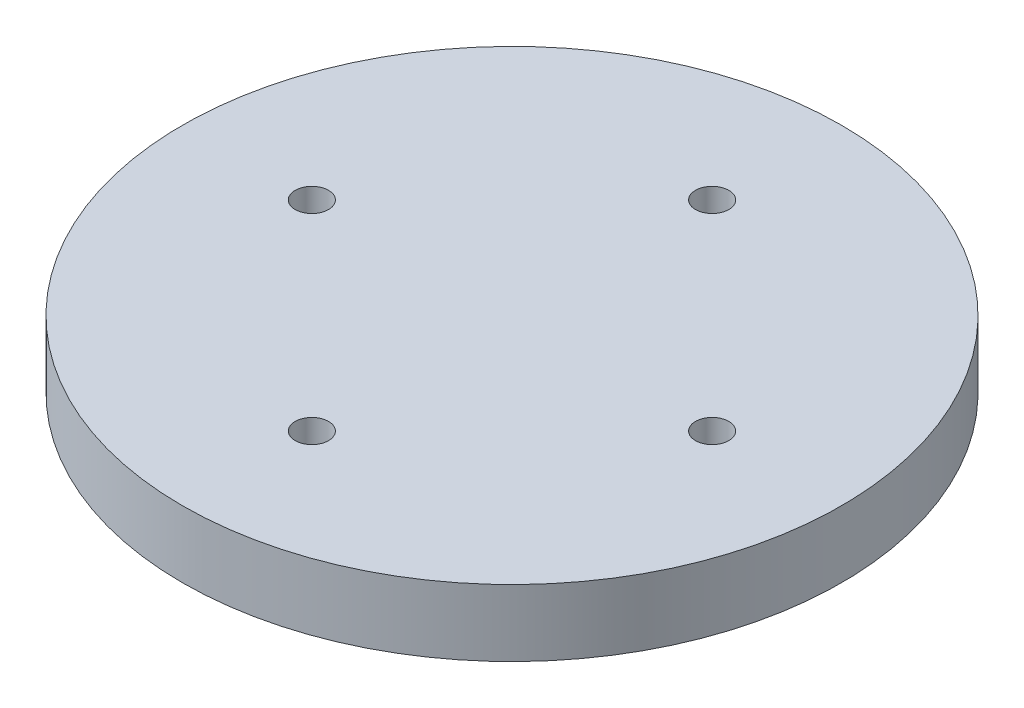
from build123d import *

# Parameters (mm, degrees)
SKETCH1_R           = 62.738
BOSS_EXTRUDE1_DEPTH = 12.7
SKETCH2_R           = 3.175
CUT_EXTRUDE1_DEPTH  = 6.35


with BuildPart() as part:
    # Sketch1 → Boss-Extrude1 (new body)
    with BuildSketch(Plane(origin=(0, 0, 0), x_dir=(1, 0, 0), z_dir=(0, 1, 0))):
        Circle(SKETCH1_R)
    extrude(amount=BOSS_EXTRUDE1_DEPTH)

    # Sketch2 → Cut-Extrude1 (cut)
    with BuildSketch(Plane(origin=(0, 12.7, 0), x_dir=(1, 0, 0), z_dir=(0, 1, 0))):
        with Locations((38.1, 0)):
            Circle(SKETCH2_R)
        with Locations((0, -38.1)):
            Circle(SKETCH2_R)
        with Locations((-38.1, 0)):
            Circle(SKETCH2_R)
        with Locations((0, 38.1)):
            Circle(SKETCH2_R)
    extrude(amount=-CUT_EXTRUDE1_DEPTH, mode=Mode.SUBTRACT)


solid = part.part
